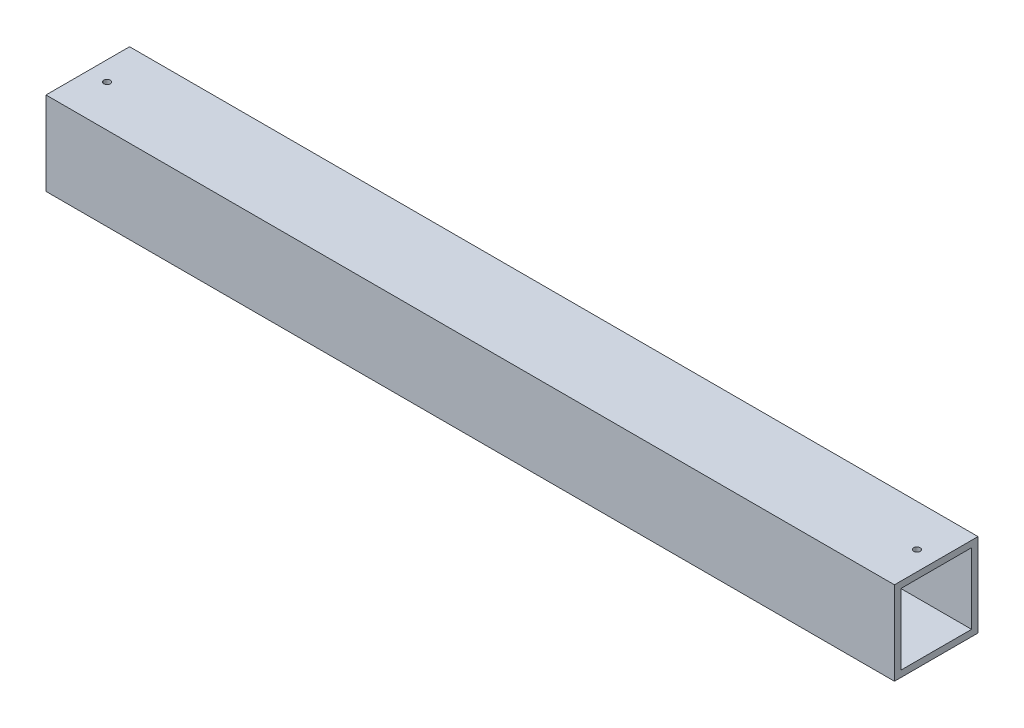
from build123d import *

# Parameters (mm, degrees)
SKETCH1_W           = 1676.4
SKETCH1_H           = 165.1
BOSS_EXTRUDE1_DEPTH = 165.1
SKETCH2_W           = 139.7
SKETCH2_H           = 139.7
CUT_EXTRUDE1_DEPTH  = 1676.4
SKETCH4_R           = 6.35
CUT_EXTRUDE3_DEPTH  = 12.7


with BuildPart() as part:
    # Sketch1 → Boss-Extrude1 (new body)
    with BuildSketch(Plane.XY):
        with Locations((838.2, 82.55)):
            Rectangle(SKETCH1_W, SKETCH1_H)
    extrude(amount=BOSS_EXTRUDE1_DEPTH)

    # Sketch2 → Cut-Extrude1 (cut)
    with BuildSketch(Plane(origin=(1676.4, 0, 0), x_dir=(0, 0, -1), z_dir=(1, 0, 0))):
        with Locations((-82.55, 82.55)):
            Rectangle(SKETCH2_W, SKETCH2_H)
    extrude(amount=-CUT_EXTRUDE1_DEPTH, mode=Mode.SUBTRACT)

    # Sketch4 → Cut-Extrude3 (cut)
    with BuildSketch(Plane(origin=(0, 165.1, 0), x_dir=(1, 0, 0), z_dir=(0, 1, 0))):
        with Locations((38.1, -82.55)):
            Circle(SKETCH4_R)
        with Locations((1638.3, -82.55)):
            Circle(SKETCH4_R)
    extrude(amount=-CUT_EXTRUDE3_DEPTH, mode=Mode.SUBTRACT)


solid = part.part
